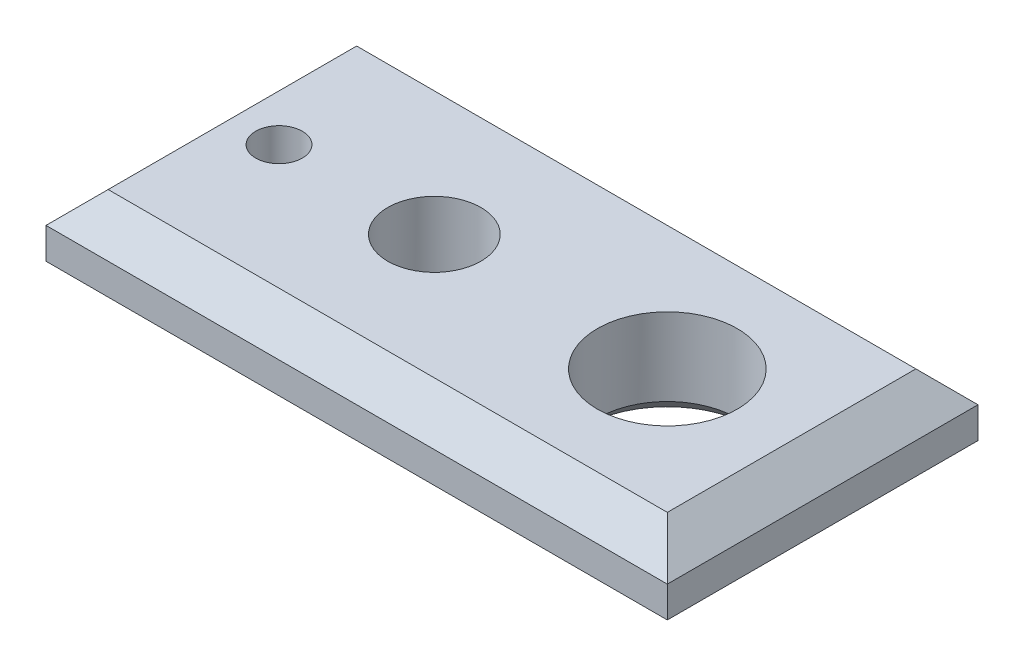
from build123d import *

# Parameters (mm, degrees)
CROQUIS1_W              = 200
CROQUIS1_H              = 100
SALIENTE_EXTRUIR1_DEPTH = 30
CHAFL_N1_SIZE           = 10
CORTAR_EXTRUIR1_REACH   = 32
CROQUIS2_R              = 7.5
CROQUIS2_R_2            = 15
CROQUIS2_R_3            = 22.5
CHAFL_N3_SIZE           = 5


with BuildPart() as part:
    # Croquis1 → Saliente-Extruir1 (new body)
    with BuildSketch(Plane(origin=(0, 0, 0), x_dir=(1, 0, 0), z_dir=(0, 1, 0))):
        Rectangle(CROQUIS1_W, CROQUIS1_H)
    extrude(amount=SALIENTE_EXTRUIR1_DEPTH)

    # Chaflán1
    chafl_n1_edges = [part.edges().sort_by_distance(p)[0] for p in [
        (-100, 30, 0),
        (0, 30, 50),
        (100, 30, 0),
        (0, 0, 50),
        (-100, 0, 0),
        (0, 0, -50),
        (100, 0, 0),
        (0, 30, -50),
    ]]
    chamfer(chafl_n1_edges, length=CHAFL_N1_SIZE)

    # Croquis2 → Cortar-Extruir1 (cut, up to next)
    with BuildSketch(Plane(origin=(0, 30, 0), x_dir=(1, 0, 0), z_dir=(0, 1, 0)), mode=Mode.PRIVATE) as cortar_extruir1_sk1:
        with Locations((-75, 0)):
            Circle(CROQUIS2_R)
    cortar_extruir1_tool1 = extrude(cortar_extruir1_sk1.sketch, amount=-CORTAR_EXTRUIR1_REACH, mode=Mode.PRIVATE) & part.part
    add(cortar_extruir1_tool1.solids().sort_by_distance((-75, 30, 0))[0], mode=Mode.SUBTRACT)
    # Croquis2 → Cortar-Extruir1 (cut, up to next)
    with BuildSketch(Plane(origin=(0, 30, 0), x_dir=(1, 0, 0), z_dir=(0, 1, 0)), mode=Mode.PRIVATE) as cortar_extruir1_sk2:
        with Locations((-25, 0)):
            Circle(CROQUIS2_R_2)
    cortar_extruir1_tool2 = extrude(cortar_extruir1_sk2.sketch, amount=-CORTAR_EXTRUIR1_REACH, mode=Mode.PRIVATE) & part.part
    add(cortar_extruir1_tool2.solids().sort_by_distance((-25, 30, 0))[0], mode=Mode.SUBTRACT)
    # Croquis2 → Cortar-Extruir1 (cut, up to next)
    with BuildSketch(Plane(origin=(0, 30, 0), x_dir=(1, 0, 0), z_dir=(0, 1, 0)), mode=Mode.PRIVATE) as cortar_extruir1_sk3:
        with Locations((50, 0)):
            Circle(CROQUIS2_R_3)
    cortar_extruir1_tool3 = extrude(cortar_extruir1_sk3.sketch, amount=-CORTAR_EXTRUIR1_REACH, mode=Mode.PRIVATE) & part.part
    add(cortar_extruir1_tool3.solids().sort_by_distance((50, 30, 0))[0], mode=Mode.SUBTRACT)

    # Chaflán3
    chafl_n3_edges = [part.edges().sort_by_distance(p)[0] for p in [
        (-82.5, 0, 0),
        (-40, 0, 0),
        (27.5, 0, 0),
    ]]
    chamfer(chafl_n3_edges, length=CHAFL_N3_SIZE)


solid = part.part
